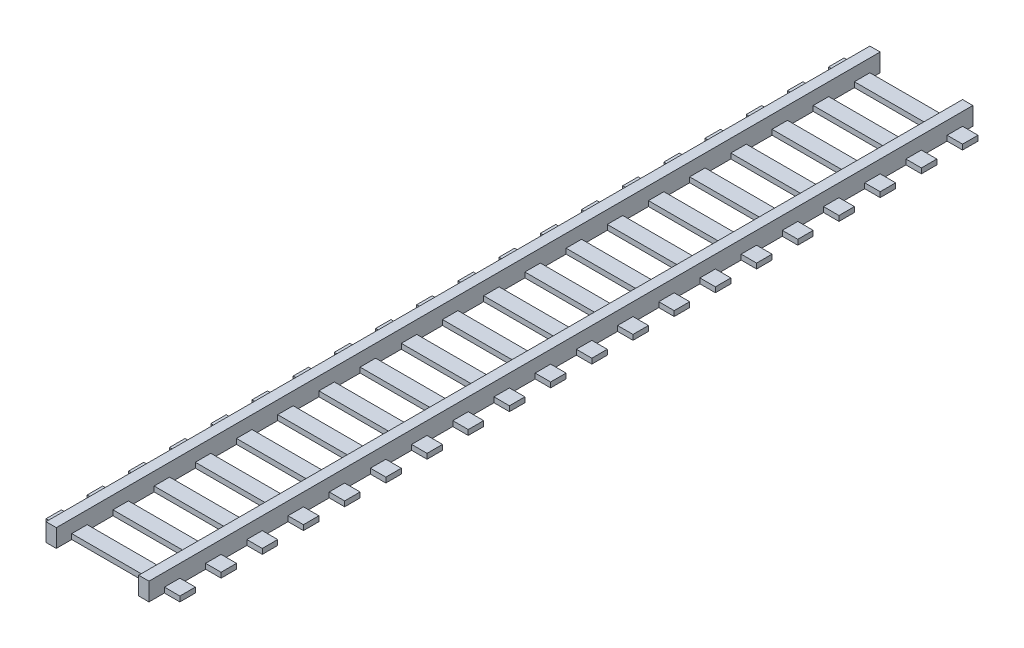
from build123d import *

# Parameters (mm, degrees)
SKETCH1_W             = 1
SKETCH1_H             = 160
BOSS_EXTRUDE1_DEPTH   = 3
BOSS_EXTRUDE1_2_DEPTH = 3
SKETCH2_W             = 1
SKETCH2_H             = 160
BOSS_EXTRUDE2_DEPTH   = 3
SKETCH3_W             = 26
SKETCH3_H             = 3
BOSS_EXTRUDE3_DEPTH   = 1
SKETCH5_W             = 2
SKETCH5_H             = 160
BOSS_EXTRUDE4_DEPTH   = 0.5


with BuildPart() as part:
    # Sketch1 → Boss-Extrude1 (new body)
    with BuildSketch(Plane(origin=(0, 0, 0), x_dir=(1, 0, 0), z_dir=(0, 1, 0))):
        with Locations((-43.187559699, -8.75)):
            Rectangle(SKETCH1_W, SKETCH1_H)
    extrude(amount=BOSS_EXTRUDE1_DEPTH)



with BuildPart() as body_2:
    # Sketch1 → Boss-Extrude1 2 (new body)
    with BuildSketch(Plane(origin=(0, 0, 0), x_dir=(1, 0, 0), z_dir=(0, 1, 0))):
        with Locations((-26.187559699, -8.75)):
            Rectangle(SKETCH1_W, SKETCH1_H)
    extrude(amount=BOSS_EXTRUDE1_2_DEPTH)


with BuildPart() as part_1:
    add(part.part)

    add(body_2.part)  # Boss-Extrude2 merges body 2
    # Sketch2 → Boss-Extrude2 (add)
    with BuildSketch(Plane.XZ):
        with Locations((-44.187559699, 8.75)):
            Rectangle(SKETCH2_W, SKETCH2_H)
        with Locations((-25.187559699, 8.75)):
            Rectangle(SKETCH2_W, SKETCH2_H)
    extrude(amount=-BOSS_EXTRUDE2_DEPTH)

    # Sketch3 → Boss-Extrude3 (add)
    with BuildSketch(Plane.XZ):
        with Locations((-34.687559699, 84.25)):
            Rectangle(SKETCH3_W, SKETCH3_H)
        with Locations((-34.687559699, 76.25)):
            Rectangle(SKETCH3_W, SKETCH3_H)
        with Locations((-34.687559699, 68.25)):
            Rectangle(SKETCH3_W, SKETCH3_H)
        with Locations((-34.687559699, 60.25)):
            Rectangle(SKETCH3_W, SKETCH3_H)
        with Locations((-34.687559699, 52.25)):
            Rectangle(SKETCH3_W, SKETCH3_H)
        with Locations((-34.687559699, 44.25)):
            Rectangle(SKETCH3_W, SKETCH3_H)
        with Locations((-34.687559699, 36.25)):
            Rectangle(SKETCH3_W, SKETCH3_H)
        with Locations((-34.687559699, 28.25)):
            Rectangle(SKETCH3_W, SKETCH3_H)
        with Locations((-34.687559699, 20.25)):
            Rectangle(SKETCH3_W, SKETCH3_H)
        with Locations((-34.687559699, 12.25)):
            Rectangle(SKETCH3_W, SKETCH3_H)
        with Locations((-34.687559699, 4.25)):
            Rectangle(SKETCH3_W, SKETCH3_H)
        with Locations((-34.687559699, -3.75)):
            Rectangle(SKETCH3_W, SKETCH3_H)
        with Locations((-34.687559699, -11.75)):
            Rectangle(SKETCH3_W, SKETCH3_H)
        with Locations((-34.687559699, -19.75)):
            Rectangle(SKETCH3_W, SKETCH3_H)
        with Locations((-34.687559699, -27.75)):
            Rectangle(SKETCH3_W, SKETCH3_H)
        with Locations((-34.687559699, -35.75)):
            Rectangle(SKETCH3_W, SKETCH3_H)
        with Locations((-34.687559699, -43.75)):
            Rectangle(SKETCH3_W, SKETCH3_H)
        with Locations((-34.687559699, -51.75)):
            Rectangle(SKETCH3_W, SKETCH3_H)
        with Locations((-34.687559699, -59.75)):
            Rectangle(SKETCH3_W, SKETCH3_H)
        with Locations((-34.687559699, -67.75)):
            Rectangle(SKETCH3_W, SKETCH3_H)
    extrude(amount=-BOSS_EXTRUDE3_DEPTH)

    # Sketch5 → Boss-Extrude4 (add)
    with BuildSketch(Plane(origin=(0, 3, 0), x_dir=(1, 0, 0), z_dir=(0, 1, 0))):
        with Locations((-43.687559699, -8.75)):
            Rectangle(SKETCH5_W, SKETCH5_H)
        with Locations((-25.687559699, -8.75)):
            Rectangle(SKETCH5_W, SKETCH5_H)
    extrude(amount=BOSS_EXTRUDE4_DEPTH)


solid = part_1.part
